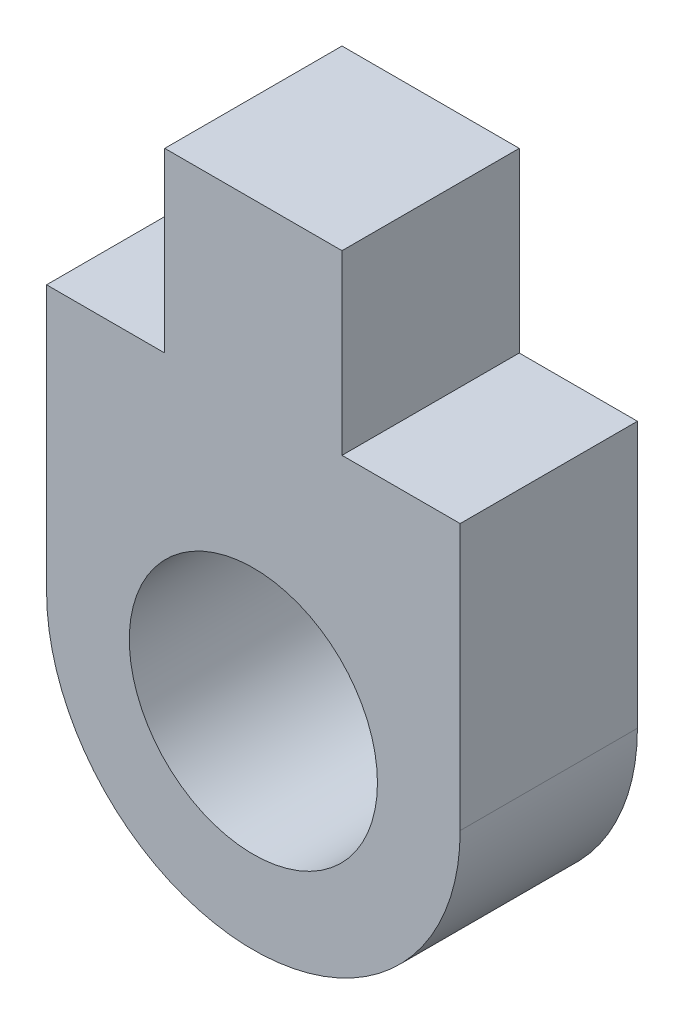
from build123d import *

# Parameters (mm, degrees)
MODEL_R                 = 2.1
SALIENTE_EXTRUIR1_DEPTH = 3


with BuildPart() as part:
    # Model → Saliente-Extruir1 (new body)
    with BuildSketch(Plane.XY):
        with BuildLine():
            Line((3.4, -0.3), (3.4, 4.2))
            Line((3.4, 4.2), (1.4, 4.2))
            Line((1.4, 4.2), (1.4, 7.2))
            Line((1.4, 7.2), (-1.6, 7.2))
            Line((-1.6, 7.2), (-1.6, 4.2))
            Line((-1.6, 4.2), (-3.6, 4.2))
            Line((-3.6, 4.2), (-3.6, -0.3))
            ThreePointArc((-3.6, -0.3), (-0.1, -3.8), (3.4, -0.3))
        make_face()
        with Locations((-0.1, -0.3)):
            Circle(MODEL_R, mode=Mode.SUBTRACT)
    extrude(amount=SALIENTE_EXTRUIR1_DEPTH)


solid = part.part
